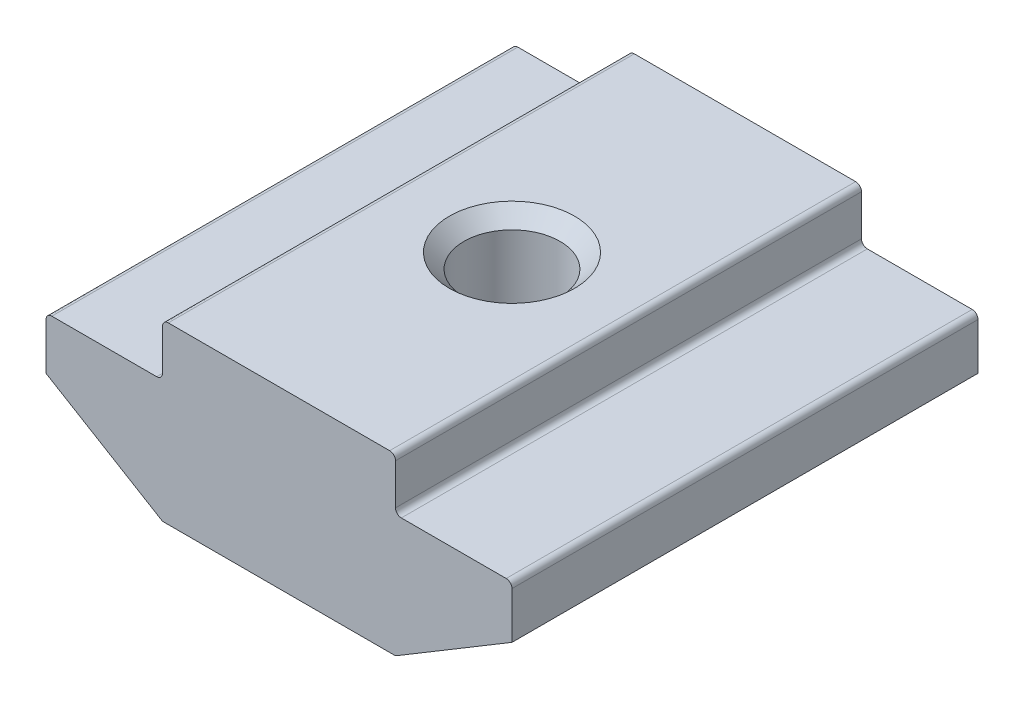
from build123d import *

# Parameters (mm, degrees)
EXTRUDE_1_DEPTH = 8
FILLET_1_R      = 0.2


with BuildPart() as part:
    # Эскиз1 → Бобышка-Вытянуть1 (new body, symmetric)
    with BuildSketch(Plane.XY):
        Polygon((4, 0), (-4, 0), (-4, -1.8), (-8, -1.8), (-8, -3.6), (-4, -6), (4, -6), (8, -3.6), (8, -1.8), (4, -1.8), align=None)
    extrude(amount=EXTRUDE_1_DEPTH, both=True)

    # Эскиз4 → Отверстие обработанное метчиком M42 (revolve, cut)
    with BuildSketch(Plane(origin=(0, 0, 0), x_dir=(0, 0, 1), z_dir=(1, 0, 0))):
        Polygon((0, 0), (0, 6), (2.15, 6), (1.65, 5.5), (1.65, 0.5), (2.15, 0), align=None)
    revolve(axis=Axis((0, 6.35, 0), (0, -1, 0)), mode=Mode.SUBTRACT)

    # Скругление1
    fillet_1_edges = [part.edges().sort_by_distance(p)[0] for p in [
        (-4, 0, 0),
        (4, 0, 0),
        (4, -1.8, 0),
        (8, -1.8, 0),
        (4, -6, 0),
        (-4, -6, 0),
        (-8, -1.8, 0),
        (-4, -1.8, 0),
    ]]
    fillet(fillet_1_edges, radius=FILLET_1_R)


solid = part.part
